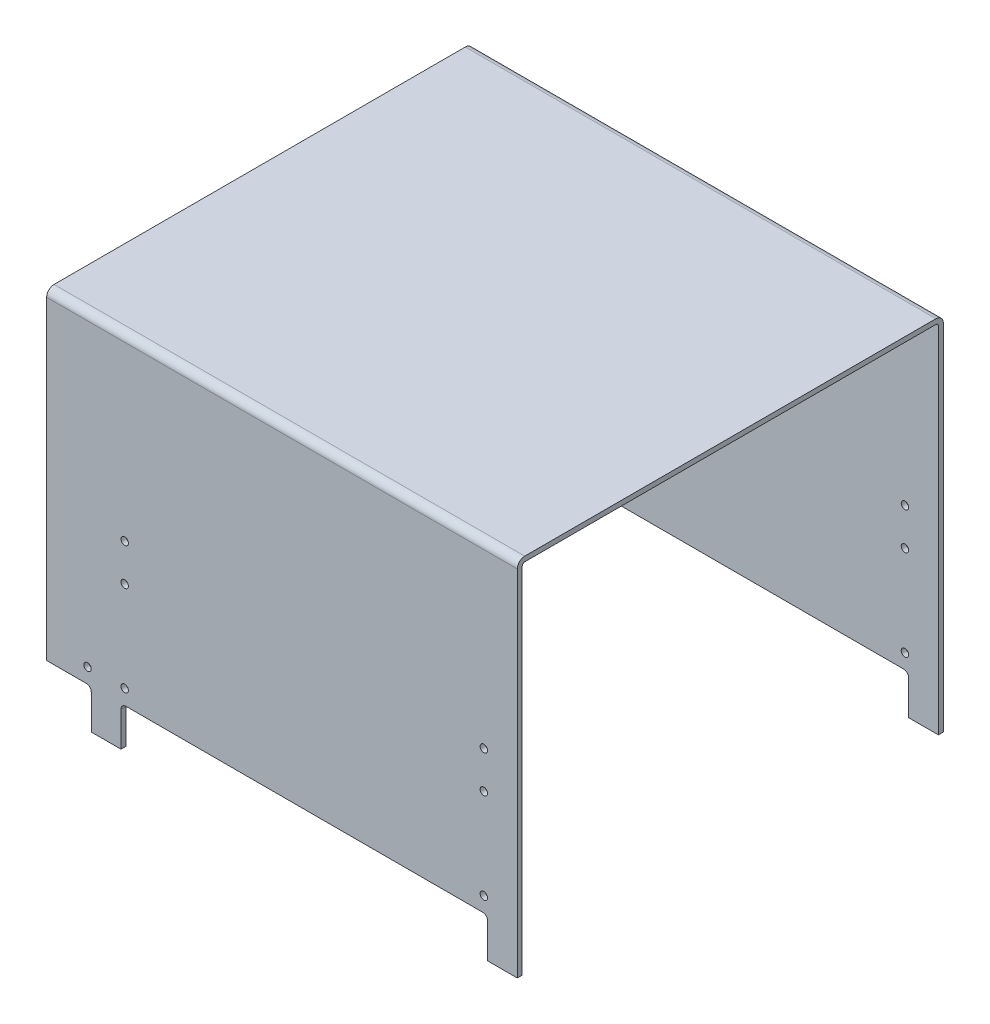
from build123d import *

# Parameters (mm, degrees)
BOSS_EXTRUDE1_DEPTH          = 6.35
BOSS_EXTRUDE1_DEPTH_BACK     = 596.9
FILLET1_R                    = 3.175
FILLET2_R                    = 9.525
SKETCH2_W                    = 469.9
SKETCH2_H                    = 50.8
SKETCH2_W_2                  = 57.15
CUT_EXTRUDE1_DEPTH           = 547.1
FILLET3_R                    = 6.35
F_3_8_0_375_DIAMETER_HOLE1_D = 9.525


with BuildPart() as part:
    # Sketch1 → Boss-Extrude1 (new body, two sides)
    with BuildSketch(Plane(origin=(0, 0, 0), x_dir=(0, 0, -1), z_dir=(1, 0, 0))) as boss_extrude1_sk:
        Polygon((0, 0), (0, 463.55), (546.1, 463.55), (546.1, 0), (539.75, 0), (539.75, 457.2), (6.35, 457.2), (6.35, 0), align=None)
    extrude(amount=BOSS_EXTRUDE1_DEPTH)
    extrude(boss_extrude1_sk.sketch, amount=-BOSS_EXTRUDE1_DEPTH_BACK)

    # Fillet1
    fillet1_edges = [part.edges().sort_by_distance(p)[0] for p in [
        (-295.275, 457.2, -539.75),
        (-295.275, 457.2, -6.35),
    ]]
    fillet(fillet1_edges, radius=FILLET1_R)

    # Fillet2
    fillet2_edges = [part.edges().sort_by_distance(p)[0] for p in [
        (-295.275, 463.55, 0),
        (-295.275, 463.55, -546.1),
    ]]
    fillet(fillet2_edges, radius=FILLET2_R)

    # Sketch2 → Cut-Extrude1 (cut, through all)
    with BuildSketch(Plane.XY):
        with Locations((-266.7, 25.4)):
            Rectangle(SKETCH2_W, SKETCH2_H)
        with Locations((-568.325, 25.4)):
            Rectangle(SKETCH2_W_2, SKETCH2_H)
    extrude(amount=-CUT_EXTRUDE1_DEPTH, mode=Mode.SUBTRACT)

    # Fillet3
    fillet3_edges = [part.edges().sort_by_distance(p)[0] for p in [
        (-31.75, 50.8, -542.925),
        (-501.65, 50.8, -542.925),
        (-31.75, 50.8, -3.175),
        (-501.65, 50.8, -3.175),
        (-539.75, 50.8, -542.925),
        (-539.75, 50.8, -3.175),
    ]]
    fillet(fillet3_edges, radius=FILLET3_R)

    # 3/8 (0.375) Diameter Hole1 (through all)
    with Locations(Plane.XY):
        with Locations((-36.5125, 69.85), (-36.5125, 185.7375), (-36.5125, 233.3625), (-496.8875, 69.85), (-496.8875, 185.7375), (-496.8875, 233.3625), (-544.5125, 69.85)):
            Hole(F_3_8_0_375_DIAMETER_HOLE1_D / 2)


solid = part.part
